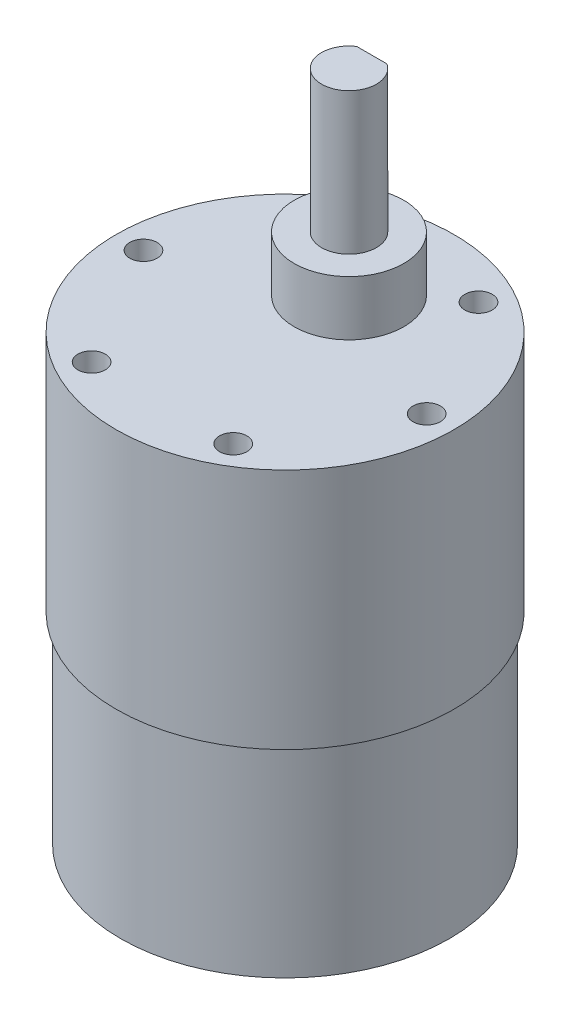
from build123d import *

# Parameters (mm, degrees)
SKETCH2_R               = 18
BOSS_EXTRUDE1_DEPTH     = 22
SKETCH3_R               = 18.5
BOSS_EXTRUDE2_DEPTH     = 26.5
SKETCH4_R               = 1.5
CUT_EXTRUDE1_DEPTH      = 6
CIRPATTERN1_COUNT       = 6
SKETCH5_R               = 6
BOSS_EXTRUDE3_DEPTH     = 6
SKETCH6_R               = 3
BOSS_EXTRUDE4_DEPTH     = 15.5
CUT_EXTRUDE2_DEPTH      = 1
CUT_EXTRUDE2_DEPTH_BACK = 12


with BuildPart() as part:
    # Sketch2 → Boss-Extrude1 (new body)
    with BuildSketch(Plane(origin=(0, 0, 0), x_dir=(1, 0, 0), z_dir=(0, 1, 0))):
        Circle(SKETCH2_R)
    extrude(amount=BOSS_EXTRUDE1_DEPTH)

    # Sketch3 → Boss-Extrude2 (add)
    with BuildSketch(Plane(origin=(0, 22, 0), x_dir=(1, 0, 0), z_dir=(0, 1, 0))):
        Circle(SKETCH3_R)
    extrude(amount=BOSS_EXTRUDE2_DEPTH)

    # Sketch4 → Cut-Extrude1 (cut)
    with BuildSketch(Plane(origin=(0, 48.5, 0), x_dir=(1, 0, 0), z_dir=(0, 1, 0))):
        with Locations((-15.5, 0)):
            Circle(SKETCH4_R)
    cut_extrude1 = extrude(amount=-CUT_EXTRUDE1_DEPTH, mode=Mode.SUBTRACT)

    # CirPattern1: Cut-Extrude1 ×6 about axis
    cirpattern1_axis = Axis((0, 0, 0), (0, 1, 0))
    for i in range(1, CIRPATTERN1_COUNT):
        add(cut_extrude1.rotate(cirpattern1_axis, i * 360 / CIRPATTERN1_COUNT), mode=Mode.SUBTRACT)

    # Sketch5 → Boss-Extrude3 (add)
    with BuildSketch(Plane(origin=(0, 48.5, 0), x_dir=(1, 0, 0), z_dir=(0, 1, 0))):
        with Locations((0, 7)):
            Circle(SKETCH5_R)
    extrude(amount=BOSS_EXTRUDE3_DEPTH)

    # Sketch6 → Boss-Extrude4 (add)
    with BuildSketch(Plane(origin=(0, 54.5, 0), x_dir=(1, 0, 0), z_dir=(0, 1, 0))):
        with Locations((0, 7)):
            Circle(SKETCH6_R)
    extrude(amount=BOSS_EXTRUDE4_DEPTH)

    # Sketch7 → Cut-Extrude2 (cut, two sides)
    with BuildSketch(Plane(origin=(0, 70, 0), x_dir=(1, 0, 0), z_dir=(0, 1, 0))) as cut_extrude2_sk:
        Polygon((-80.661403086, 9.5), (-1.6583, 9.5), (1.6583, 9.5), (80.661403086, 9.5), (80.661403086, 167.506206173), (-80.661403086, 167.506206173), align=None)
    extrude(amount=CUT_EXTRUDE2_DEPTH, mode=Mode.SUBTRACT)
    extrude(cut_extrude2_sk.sketch, amount=-CUT_EXTRUDE2_DEPTH_BACK, mode=Mode.SUBTRACT)


solid = part.part
